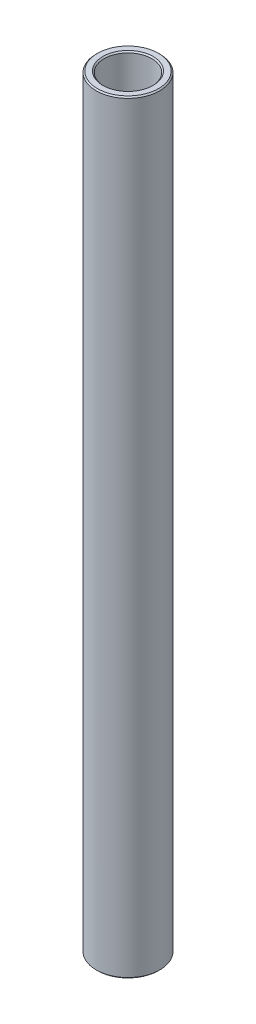
from build123d import *

# Parameters (mm, degrees)
SKETCH1_W     = 1.5875
SKETCH1_H     = 152.4
CHAMFER1_SIZE = 0.254


with BuildPart() as part:
    # Sketch1 → Revolve1 (revolve)
    with BuildSketch(Plane.XY):
        with Locations((5.55625, 0)):
            Rectangle(SKETCH1_W, SKETCH1_H)
    revolve(axis=Axis((0, 11.60859375, 0), (0, -1, 0)))

    # Chamfer1
    chamfer1_edges = [part.edges().sort_by_distance(p)[0] for p in [
        (-4.7625, -76.2, 0),
        (-6.35, -76.2, 0),
        (-6.35, 76.2, 0),
        (-4.7625, 76.2, 0),
    ]]
    chamfer(chamfer1_edges, length=CHAMFER1_SIZE)


solid = part.part
